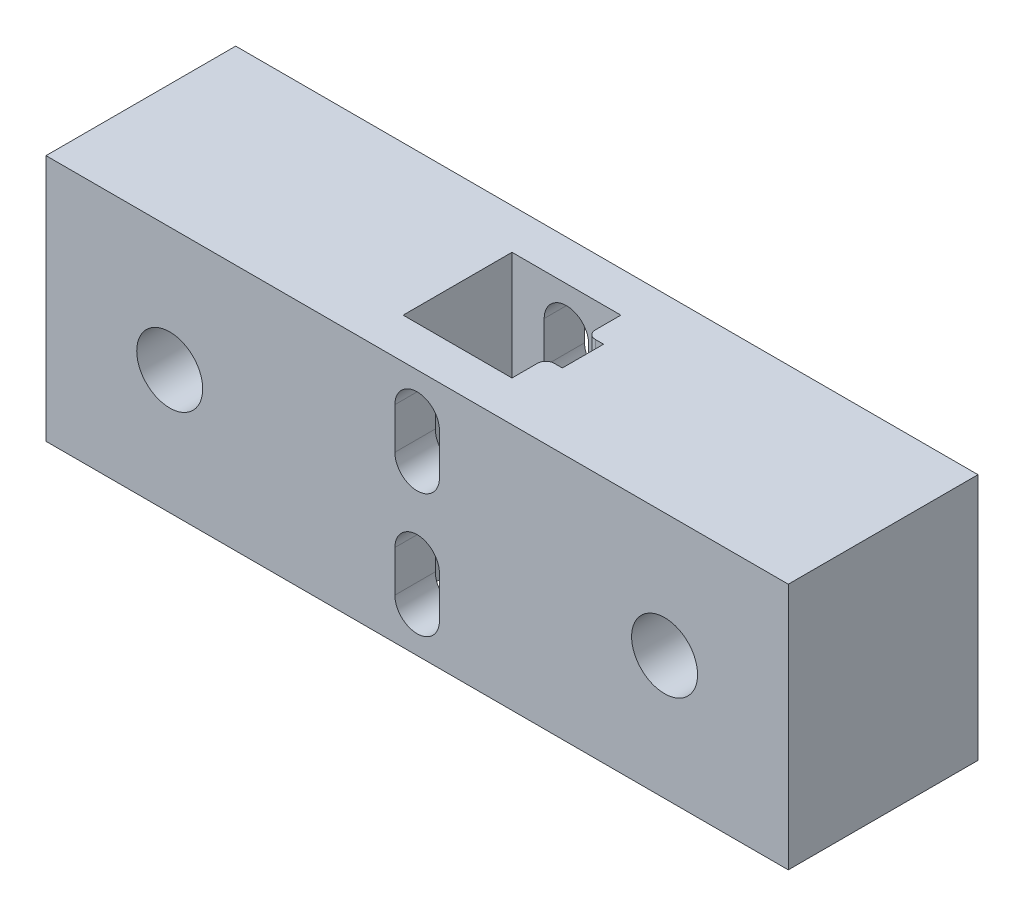
from build123d import *

# Parameters (mm, degrees)
ESQUISSE1_W             = 90
ESQUISSE1_H             = 30
BOSS_EXTRU_1_DEPTH      = 23
ESQUISSE2_W             = 13.2
ESQUISSE2_H             = 13.2
ESQUISSE2_W_2           = 2
ESQUISSE2_H_2           = 5
ENL_V_MAT_EXTRU_1_DEPTH = 31
ESQUISSE3_R             = 4
ENL_V_MAT_EXTRU_2_DEPTH = 24
ENL_V_MAT_EXTRU_3_DEPTH = 24
CONG_1_R                = 1


with BuildPart() as part:
    # Esquisse1 → Boss.-Extru.1 (new body)
    with BuildSketch(Plane.XY):
        with Locations((40.889968792, -13.091136671)):
            Rectangle(ESQUISSE1_W, ESQUISSE1_H)
    extrude(amount=BOSS_EXTRU_1_DEPTH)

    # Esquisse2 → Enlèv. mat.-Extru.1 (cut, through all)
    with BuildSketch(Plane(origin=(0, 1.908863329, 0), x_dir=(1, 0, 0), z_dir=(0, 1, 0))):
        with Locations((40.889968792, -11.5)):
            Rectangle(ESQUISSE2_W, ESQUISSE2_H)
        with Locations((48.489968792, -11.5)):
            Rectangle(ESQUISSE2_W_2, ESQUISSE2_H_2)
    extrude(amount=-ENL_V_MAT_EXTRU_1_DEPTH, mode=Mode.SUBTRACT)

    # Esquisse3 → Enlèv. mat.-Extru.2 (cut, through all)
    with BuildSketch(Plane(origin=(0, 0, 0), x_dir=(-1, 0, 0), z_dir=(0, 0, -1))):
        with Locations((-10.889968792, -13.091136671)):
            Circle(ESQUISSE3_R)
        with Locations((-70.889968792, -13.091136671)):
            Circle(ESQUISSE3_R)
    extrude(amount=-ENL_V_MAT_EXTRU_2_DEPTH, mode=Mode.SUBTRACT)

    # Esquisse4 → Enlèv. mat.-Extru.3 (cut, through all)
    with BuildSketch(Plane(origin=(0, 0, 0), x_dir=(-1, 0, 0), z_dir=(0, 0, -1))):
        with BuildLine():
            ThreePointArc((-38.189968792, -8.091136671), (-40.889968792, -10.791136671), (-43.589968792, -8.091136671))
            Line((-43.589968792, -8.091136671), (-43.589968792, -3.091136671))
            ThreePointArc((-43.589968792, -3.091136671), (-40.889968792, -0.391136671), (-38.189968792, -3.091136671))
            Line((-38.189968792, -3.091136671), (-38.189968792, -8.091136671))
        make_face()
        with BuildLine():
            Line((-43.589968792, -23.091136671), (-43.589968792, -18.091136671))
            ThreePointArc((-43.589968792, -18.091136671), (-40.889968792, -15.391136671), (-38.189968792, -18.091136671))
            Line((-38.189968792, -18.091136671), (-38.189968792, -23.091136671))
            ThreePointArc((-38.189968792, -23.091136671), (-40.889968792, -25.791136671), (-43.589968792, -23.091136671))
        make_face()
    extrude(amount=-ENL_V_MAT_EXTRU_3_DEPTH, mode=Mode.SUBTRACT)

    # Congé1
    cong_1_edges = [part.edges().sort_by_distance(p)[0] for p in [
        (47.489968792, -13.091136671, 9),
        (47.489968792, -13.091136671, 14),
    ]]
    fillet(cong_1_edges, radius=CONG_1_R)


solid = part.part
